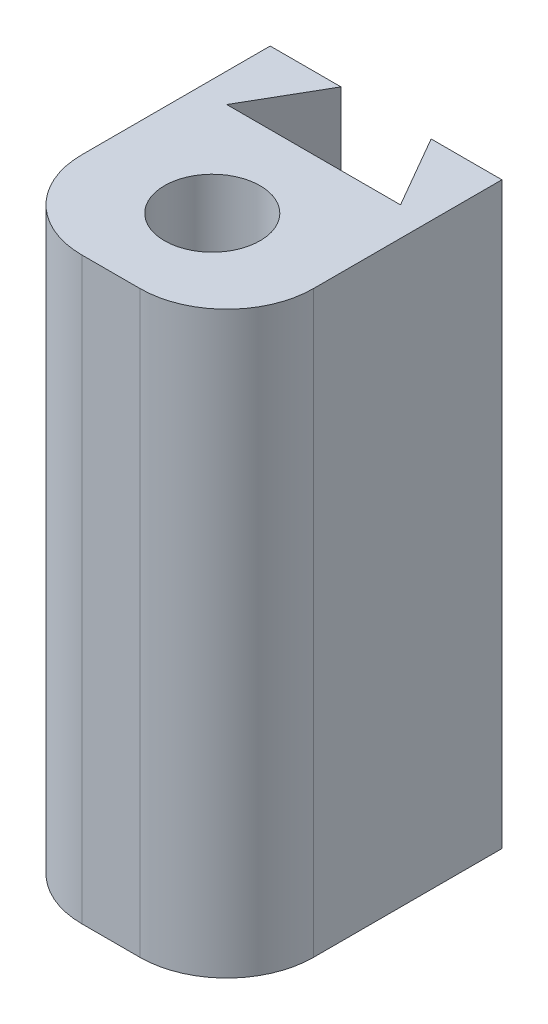
from build123d import *

# Parameters (mm, degrees)
UPPER_23_W                      = 2.5
UPPER_23_H                      = 1
BOSS_EXTRUDE9_DEPTH             = 20
SKETCH50_W                      = 8
SKETCH50_H                      = 20
BOSS_EXTRUDE10_DEPTH            = 6
TAP_DRILL_FOR_M4X0_7_TAP2_D     = 3.3
TAP_DRILL_FOR_M4X0_7_TAP2_DEPTH = 20
FILLET1_R                       = 3


with BuildPart() as part:
    # upper_23 → Boss-Extrude9 (new body)
    with BuildSketch(Plane(origin=(0, -19, 0), x_dir=(1, 0, 0), z_dir=(0, 1, 0))):
        Polygon((-4, 12), (-4, 9.5), (-3, 9.5), (-1.556624327, 12), align=None)
        Polygon((-3, 9.5), (-4, 9.5), (-4, 8.5), (-1.25, 8.5), (-1.25, 9.5), (-2.5, 9.5), align=None)
        with Locations((0, 9)):
            Rectangle(UPPER_23_W, UPPER_23_H)
        Polygon((4, 8.5), (4, 9.5), (3, 9.5), (2.5, 9.5), (1.25, 9.5), (1.25, 8.5), align=None)
        Polygon((3, 9.5), (4, 9.5), (4, 12), (1.556624327, 12), align=None)
    extrude(amount=BOSS_EXTRUDE9_DEPTH)

    # Sketch50 → Boss-Extrude10 (add)
    with BuildSketch(Plane.XY.offset(-8.5)):
        with Locations((0, -9)):
            Rectangle(SKETCH50_W, SKETCH50_H)
    extrude(amount=BOSS_EXTRUDE10_DEPTH)

    # Tap Drill for M4x0.7 Tap2
    with Locations(Plane(origin=(0, 1, 0), x_dir=(1, 0, 0), z_dir=(0, 1, 0))):
        with Locations((0, 6)):
            Hole(TAP_DRILL_FOR_M4X0_7_TAP2_D / 2, depth=TAP_DRILL_FOR_M4X0_7_TAP2_DEPTH)

    # Fillet1
    fillet1_edges = [part.edges().sort_by_distance(p)[0] for p in [
        (-4, -9, -2.5),
        (4, -9, -2.5),
    ]]
    fillet(fillet1_edges, radius=FILLET1_R)


solid = part.part
